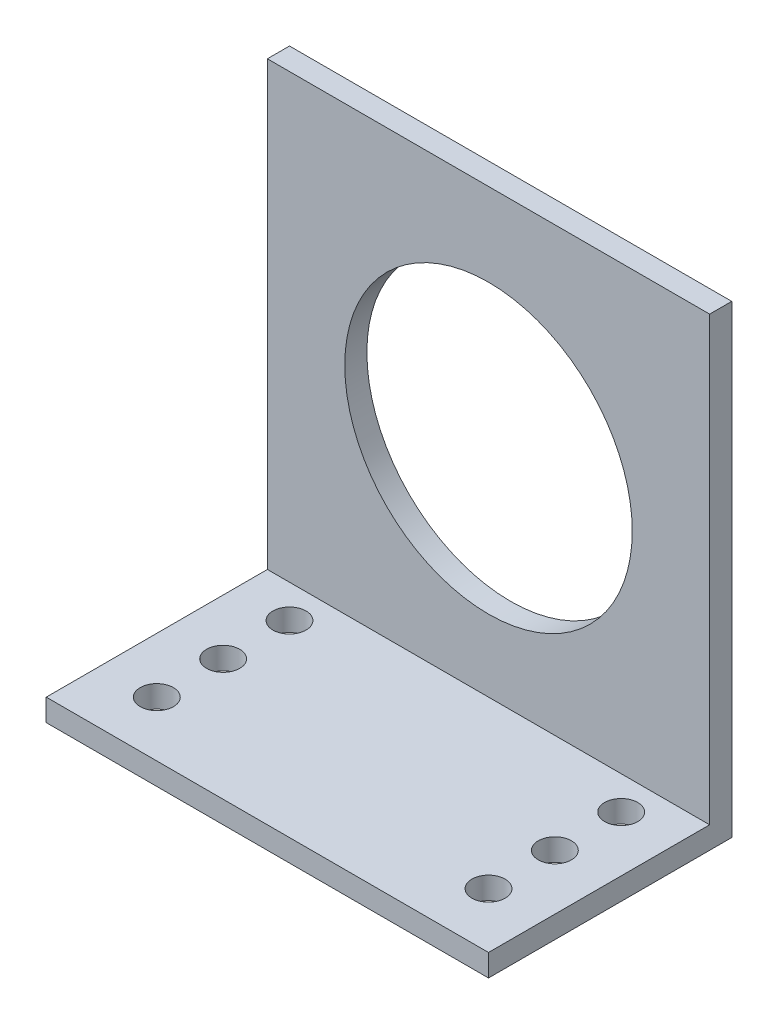
from build123d import *

# Parameters (mm, degrees)
BOSS_EXTRUDE1_DEPTH = 40
SKETCH3_R           = 13
CUT_EXTRUDE1_DEPTH  = 3
SKETCH4_R           = 1.5
CUT_EXTRUDE2_DEPTH  = 3


with BuildPart() as part:
    # Sketch2 → Boss-Extrude1 (new body)
    with BuildSketch(Plane(origin=(0, 0, 0), x_dir=(0, 0, -1), z_dir=(1, 0, 0))):
        Polygon((0, 0), (22, 0), (22, 42), (20, 42), (20, 2), (0, 2), align=None)
    extrude(amount=BOSS_EXTRUDE1_DEPTH)

    # Sketch3 → Cut-Extrude1 (cut, through all)
    with BuildSketch(Plane.XY.offset(-20)):
        with Locations((20, 21.5)):
            Circle(SKETCH3_R)
    extrude(amount=-CUT_EXTRUDE1_DEPTH, mode=Mode.SUBTRACT)

    # Sketch4 → Cut-Extrude2 (cut, through all)
    with BuildSketch(Plane(origin=(0, 2, 0), x_dir=(1, 0, 0), z_dir=(0, 1, 0))):
        with Locations((35, 5)):
            Circle(SKETCH4_R)
        with Locations((5, 5)):
            Circle(SKETCH4_R)
        with Locations((5, 11)):
            Circle(SKETCH4_R)
        with Locations((5, 17)):
            Circle(SKETCH4_R)
        with Locations((35, 11)):
            Circle(SKETCH4_R)
        with Locations((35, 17)):
            Circle(SKETCH4_R)
    extrude(amount=-CUT_EXTRUDE2_DEPTH, mode=Mode.SUBTRACT)


solid = part.part
